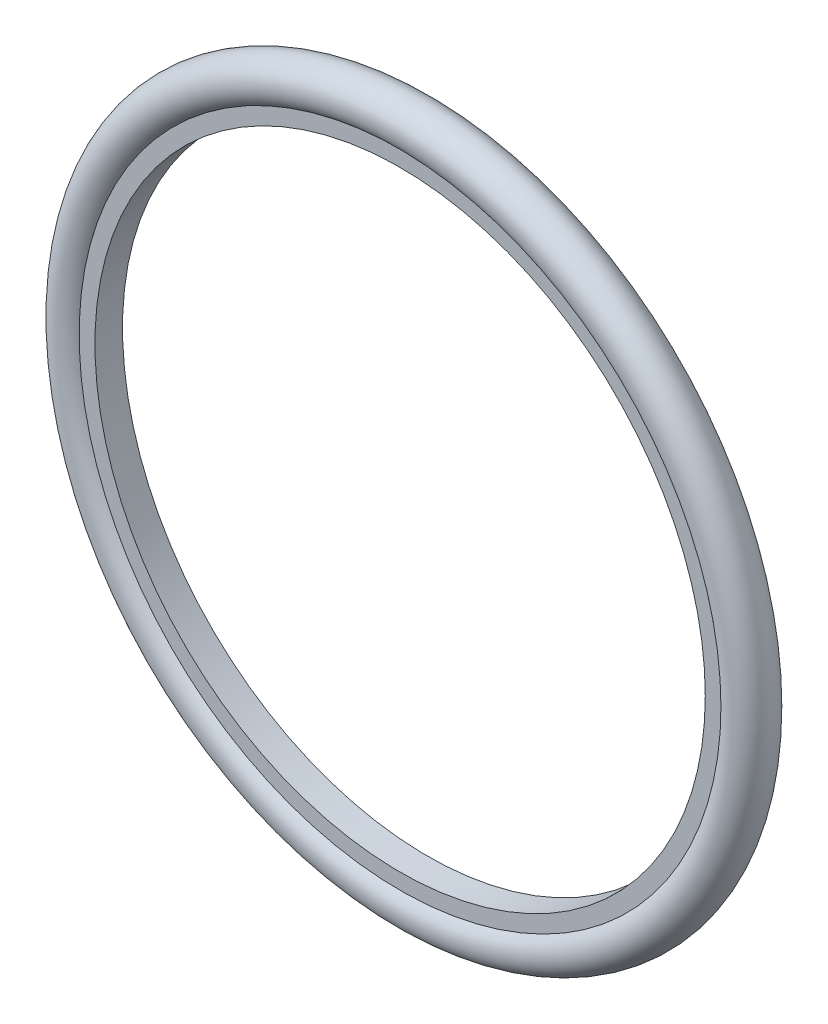
from build123d import *


with BuildPart() as part:
    # Croquis3 → Revolución1 (revolve)
    with BuildSketch(Plane(origin=(0, 0, 0), x_dir=(0, 0, -1), z_dir=(1, 0, 0))):
        with BuildLine():
            Line((12.192, 269.875), (-12.192, 269.875))
            Line((-12.192, 269.875), (-12.192, 283.812457993))
            ThreePointArc((-12.192, 283.812457993), (0, 317.5), (12.192, 283.812457993))
            Line((12.192, 283.812457993), (12.192, 269.875))
        make_face()
    revolve(axis=Axis((0, 0, 0), (0, 0, -1)))


solid = part.part
